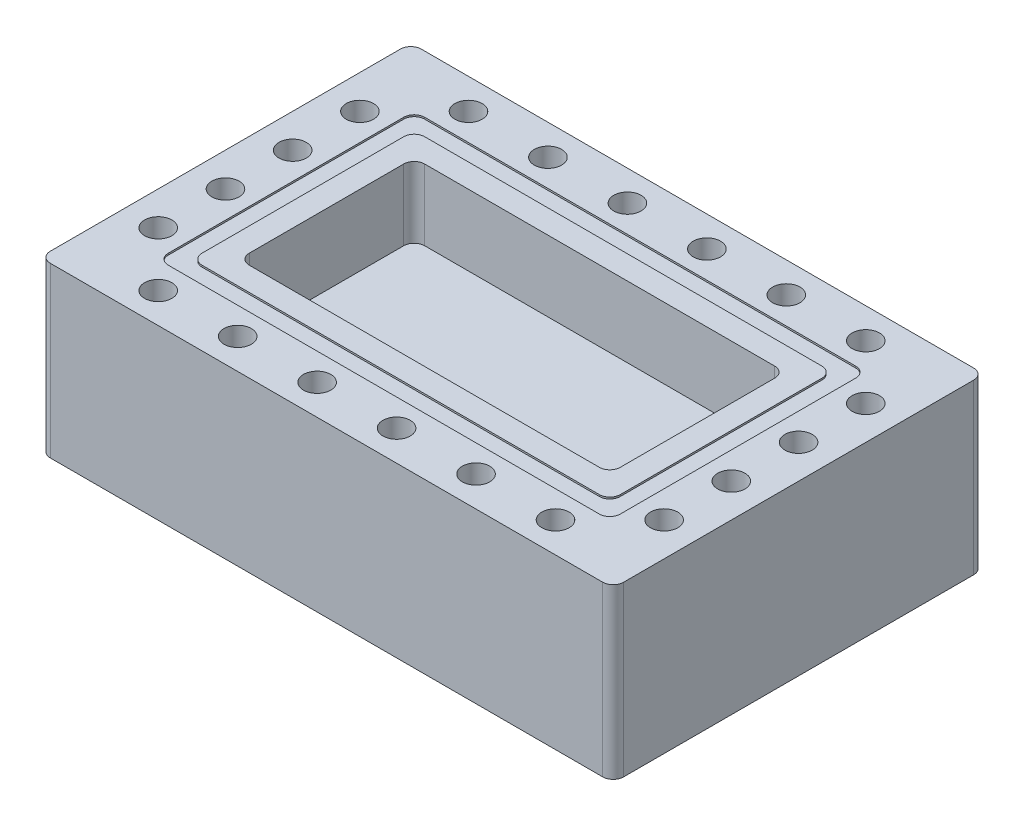
from build123d import *

# Parameters (mm, degrees)
SKETCH1_W           = 85
SKETCH1_H           = 55
BOSS_EXTRUDE1_DEPTH = 25
SKETCH2_W           = 55
SKETCH2_H           = 26
CUT_EXTRUDE1_DEPTH  = 10.5
FILLET1_R           = 1.55
SKETCH3_W           = 67
SKETCH3_H           = 38
SKETCH3_W_2         = 62
SKETCH3_H_2         = 33
CUT_EXTRUDE2_DEPTH  = 0.25
FILLET2_R           = 1.55
SKETCH5_R           = 2.025
CUT_EXTRUDE4_DEPTH  = 26


with BuildPart() as part:
    # Sketch1 → Boss-Extrude1 (new body)
    with BuildSketch(Plane(origin=(0, 0, 0), x_dir=(1, 0, 0), z_dir=(0, 1, 0))):
        with Locations((42.5, 27.5)):
            Rectangle(SKETCH1_W, SKETCH1_H)
    extrude(amount=BOSS_EXTRUDE1_DEPTH)

    # Sketch2 → Cut-Extrude1 (cut)
    with BuildSketch(Plane(origin=(0, 25, 0), x_dir=(1, 0, 0), z_dir=(0, 1, 0))):
        with Locations((42.5, 27.5)):
            Rectangle(SKETCH2_W, SKETCH2_H)
    extrude(amount=-CUT_EXTRUDE1_DEPTH, mode=Mode.SUBTRACT)

    # Fillet1
    fillet1_edges = [part.edges().sort_by_distance(p)[0] for p in [
        (15, 19.75, -14.5),
        (15, 19.75, -40.5),
        (70, 19.75, -40.5),
        (70, 19.75, -14.5),
        (0, 12.5, -55),
        (85, 12.5, -55),
        (85, 12.5, 0),
        (0, 12.5, 0),
    ]]
    fillet(fillet1_edges, radius=FILLET1_R)

    # Sketch3 → Cut-Extrude2 (cut)
    with BuildSketch(Plane(origin=(0, 25, 0), x_dir=(1, 0, 0), z_dir=(0, 1, 0))):
        with Locations((42.5, 27.5)):
            Rectangle(SKETCH3_W, SKETCH3_H)
        with Locations((42.5, 27.5)):
            Rectangle(SKETCH3_W_2, SKETCH3_H_2, mode=Mode.SUBTRACT)
    extrude(amount=-CUT_EXTRUDE2_DEPTH, mode=Mode.SUBTRACT)

    # Fillet2
    fillet2_edges = [part.edges().sort_by_distance(p)[0] for p in [
        (9, 24.875, -8.5),
        (9, 24.875, -46.5),
        (76, 24.875, -46.5),
        (76, 24.875, -8.5),
        (11.5, 24.875, -44),
        (73.5, 24.875, -44),
        (73.5, 24.875, -11),
        (11.5, 24.875, -11),
    ]]
    fillet(fillet2_edges, radius=FILLET2_R)

    # Sketch5 → Cut-Extrude4 (cut, through all)
    with BuildSketch(Plane(origin=(0, 25, 0), x_dir=(1, 0, 0), z_dir=(0, 1, 0))):
        with Locations((5, 42.45)):
            Circle(SKETCH5_R)
        with Locations((5, 12.55)):
            Circle(SKETCH5_R)
        with Locations((13.05, 4.5)):
            Circle(SKETCH5_R)
        with Locations((71.95, 4.5)):
            Circle(SKETCH5_R)
        with Locations((24.83, 4.5)):
            Circle(SKETCH5_R)
        with Locations((36.61, 4.5)):
            Circle(SKETCH5_R)
        with Locations((48.39, 4.5)):
            Circle(SKETCH5_R)
        with Locations((60.17, 4.5)):
            Circle(SKETCH5_R)
        with Locations((5, 32.483333333)):
            Circle(SKETCH5_R)
        with Locations((5, 22.516666667)):
            Circle(SKETCH5_R)
        with Locations((80, 42.45)):
            Circle(SKETCH5_R)
        with Locations((80, 12.55)):
            Circle(SKETCH5_R)
        with Locations((80, 22.516666667)):
            Circle(SKETCH5_R)
        with Locations((80, 32.483333333)):
            Circle(SKETCH5_R)
        with Locations((13.05, 50.5)):
            Circle(SKETCH5_R)
        with Locations((24.83, 50.5)):
            Circle(SKETCH5_R)
        with Locations((36.61, 50.5)):
            Circle(SKETCH5_R)
        with Locations((48.39, 50.5)):
            Circle(SKETCH5_R)
        with Locations((60.17, 50.5)):
            Circle(SKETCH5_R)
        with Locations((71.95, 50.5)):
            Circle(SKETCH5_R)
    extrude(amount=-CUT_EXTRUDE4_DEPTH, mode=Mode.SUBTRACT)


solid = part.part
